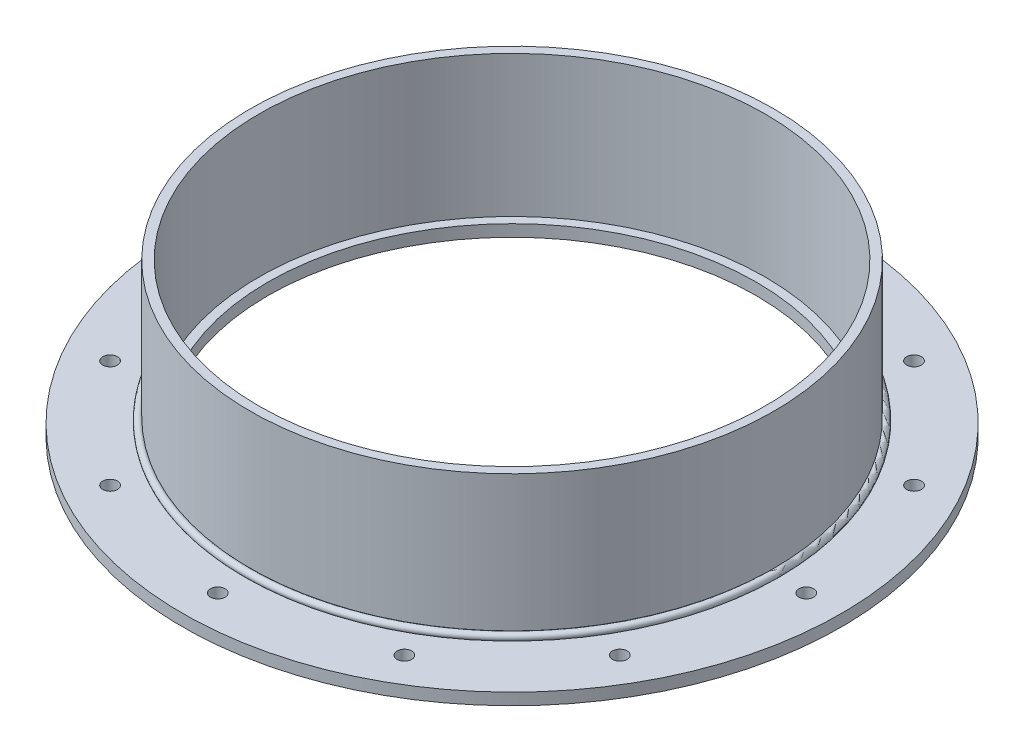
from build123d import *

# Parameters (mm, degrees)
SKETCH1_W          = 46.0375
SKETCH1_H          = 6.35
SKETCH2_W          = 4.7625
SKETCH2_H          = 76.2
SKETCH4_R          = 3.96875
CUT_EXTRUDE1_DEPTH = 7.35
CIRPATTERN1_COUNT  = 12


with BuildPart() as part:
    # Sketch1 → Revolve1 (revolve)
    with BuildSketch(Plane.XY, mode=Mode.PRIVATE) as revolve1_sk:
        with Locations((-154.78125, 3.175)):
            Rectangle(SKETCH1_W, SKETCH1_H)
    revolve(revolve1_sk.sketch.rotate(Axis((0, 0, 0), (0, 1, 0)), 270), axis=Axis((0, 0, 0), (0, 1, 0)))  # turned: the seam where the file's is

    # Sketch4 → Cut-Extrude1 (cut, through all)
    with BuildSketch(Plane(origin=(0, 6.35, 0), x_dir=(1, 0, 0), z_dir=(0, 1, 0))):
        with Locations(Location((0, 158.75, 0), (0, 0, 270))):  # turned: the seam where the file's is
            Circle(SKETCH4_R)
    cut_extrude1 = extrude(amount=-CUT_EXTRUDE1_DEPTH, mode=Mode.SUBTRACT)

    # CirPattern1: Cut-Extrude1 ×12 about axis
    cirpattern1_axis = Axis((0, 0, 0), (0, 1, 0))
    for i in range(1, CIRPATTERN1_COUNT):
        add(cut_extrude1.rotate(cirpattern1_axis, i * 360 / CIRPATTERN1_COUNT), mode=Mode.SUBTRACT)


with BuildPart() as body_2:
    # Sketch2 → Revolve2 (revolve)
    with BuildSketch(Plane.XY, mode=Mode.PRIVATE) as revolve2_sk:
        with Locations((-138.90625, 44.45)):
            Rectangle(SKETCH2_W, SKETCH2_H)
    revolve(revolve2_sk.sketch.rotate(Axis((0, 0, 0), (0, 1, 0)), 270), axis=Axis((0, 0, 0), (0, 1, 0)))  # turned: the seam where the file's is


with BuildPart() as body_3:
    # Sketch3 → Revolve3 (revolve)
    with BuildSketch(Plane.XY, mode=Mode.PRIVATE) as revolve3_sk:
        with BuildLine():
            Line((-141.2875, 6.35), (-144.073275819, 6.35))
            ThreePointArc((-144.073275819, 6.35), (-143.914037909, 8.976537909), (-141.2875, 9.135775819))
            Line((-141.2875, 9.135775819), (-141.2875, 6.35))
        make_face()
    revolve(revolve3_sk.sketch.rotate(Axis((0, 0, 0), (0, 1, 0)), 270), axis=Axis((0, 0, 0), (0, 1, 0)))  # turned: the seam where the file's is


solid = Compound([part.part, body_2.part, body_3.part])
